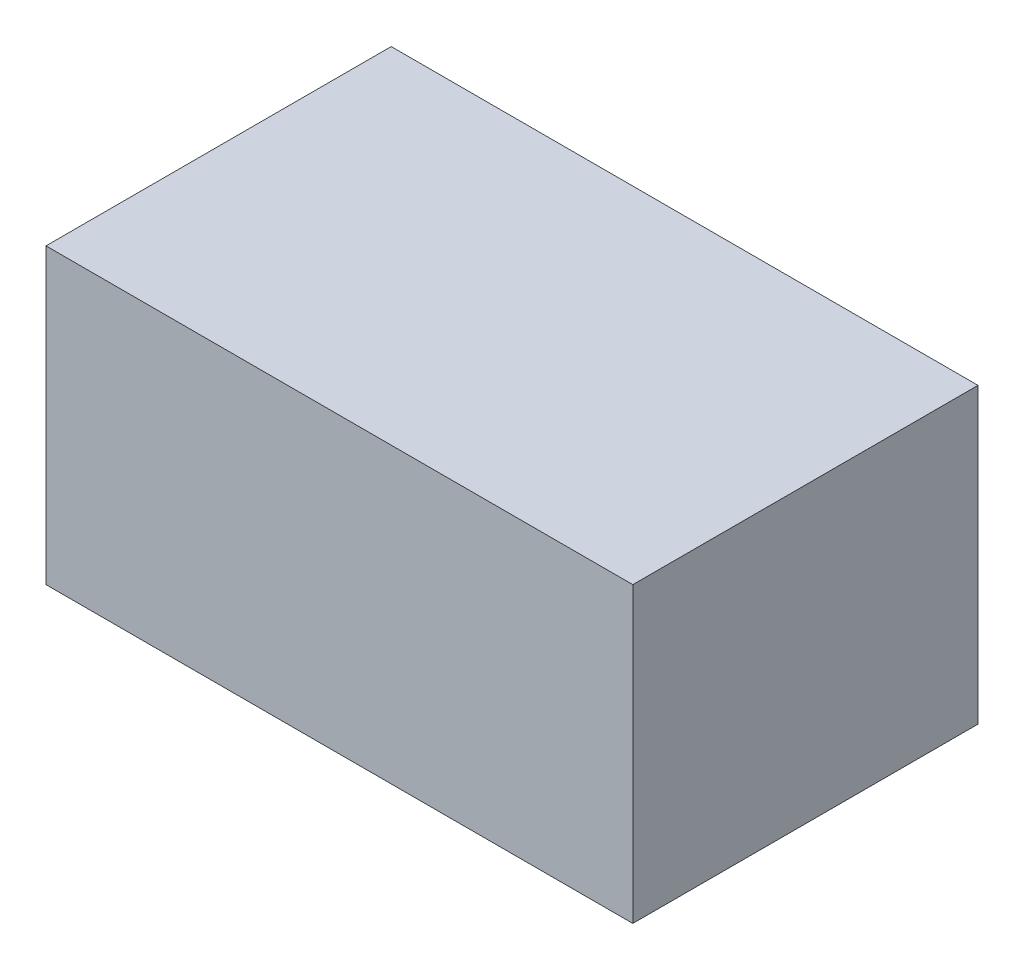
from build123d import *

# Parameters (mm, degrees)
SKETCH1_W           = 0.34
SKETCH1_H           = 0.2
BOSS_EXTRUDE1_DEPTH = 0.17


with BuildPart() as part:
    # Sketch1 → Boss-Extrude1 (new body)
    with BuildSketch(Plane(origin=(0, 0, 0), x_dir=(1, 0, 0), z_dir=(0, 1, 0))):
        Rectangle(SKETCH1_W, SKETCH1_H)
    extrude(amount=BOSS_EXTRUDE1_DEPTH)


solid = part.part
